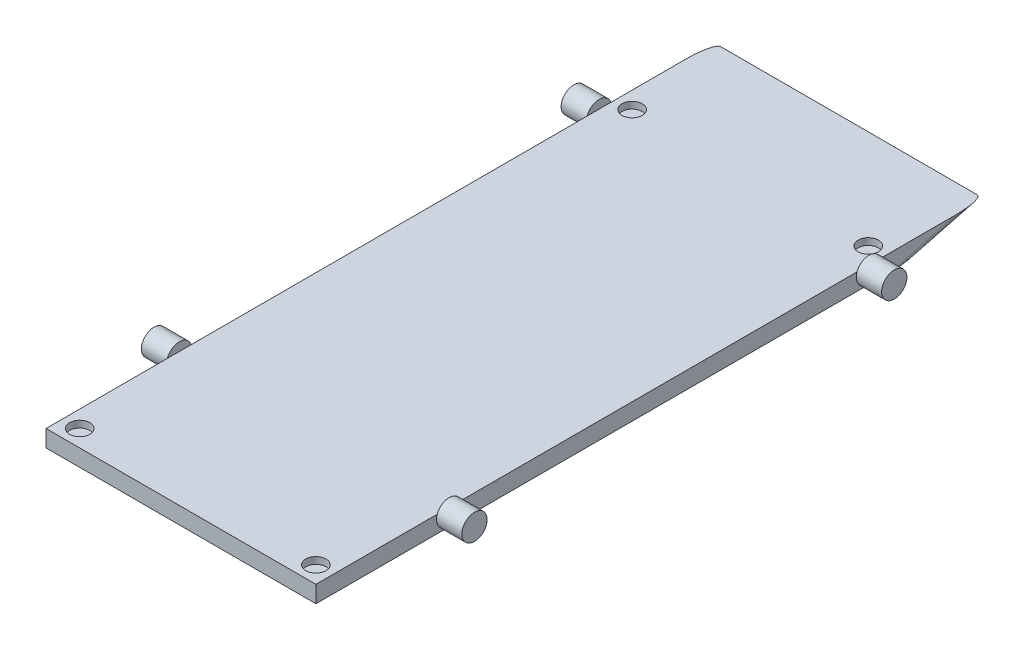
from build123d import *

# Parameters (mm, degrees)
SKETCH1_W           = 80
SKETCH1_H           = 198
BOSS_EXTRUDE1_DEPTH = 5
SKETCH2_R           = 3.75
BOSS_EXTRUDE2_DEPTH = 7.5
CUT_EXTRUDE1_DEPTH  = 88.5
FILLET2_R           = 2
CUT_EXTRUDE2_START  = -5
SKETCH4_R           = 3
CUT_EXTRUDE2_DEPTH  = 2


with BuildPart() as part:
    # Sketch1 → Boss-Extrude1 (new body)
    with BuildSketch(Plane(origin=(0, 0, 0), x_dir=(1, 0, 0), z_dir=(0, 1, 0))):
        Rectangle(SKETCH1_W, SKETCH1_H)
    extrude(amount=BOSS_EXTRUDE1_DEPTH)

    # Sketch2 → Boss-Extrude2 (add)
    with BuildSketch(Plane.ZY.offset(40)):
        with Locations((-64.928905814, 3.75)):
            Circle(SKETCH2_R)
        with Locations((59.5, 3.75)):
            Circle(SKETCH2_R)
    boss_extrude2 = extrude(amount=BOSS_EXTRUDE2_DEPTH)

    # Mirror1: Boss-Extrude2 across plane
    add(boss_extrude2.mirror(Plane(origin=(0, 0, 0), x_dir=(0, 0, 1), z_dir=(1, 0, 0))))

    # Sketch3 → Cut-Extrude1 (cut, through all)
    with BuildSketch(Plane.ZY.offset(40)):
        Polygon((-99, 5), (-72.932513489, -1.759148434), (-103.799311702, -1.759148434), align=None)
    extrude(amount=-CUT_EXTRUDE1_DEPTH, mode=Mode.SUBTRACT)

    # Fillet2
    fillet2_edges = [part.edges().sort_by_distance(p)[0] for p in [
        (40, 2.5, -89.358442796),
        (-40, 2.5, -89.358442796),
    ]]
    fillet(fillet2_edges, radius=FILLET2_R)

    # Sketch4 → Cut-Extrude2 (cut)
    with BuildSketch(Plane.XZ.offset(CUT_EXTRUDE2_START)):
        with Locations((-35, -69.716885591)):
            Circle(SKETCH4_R)
        with Locations((35, -69.716885591)):
            Circle(SKETCH4_R)
        with Locations((-35, 94)):
            Circle(SKETCH4_R)
        with Locations((35, 94)):
            Circle(SKETCH4_R)
    extrude(amount=CUT_EXTRUDE2_DEPTH, mode=Mode.SUBTRACT)


solid = part.part
